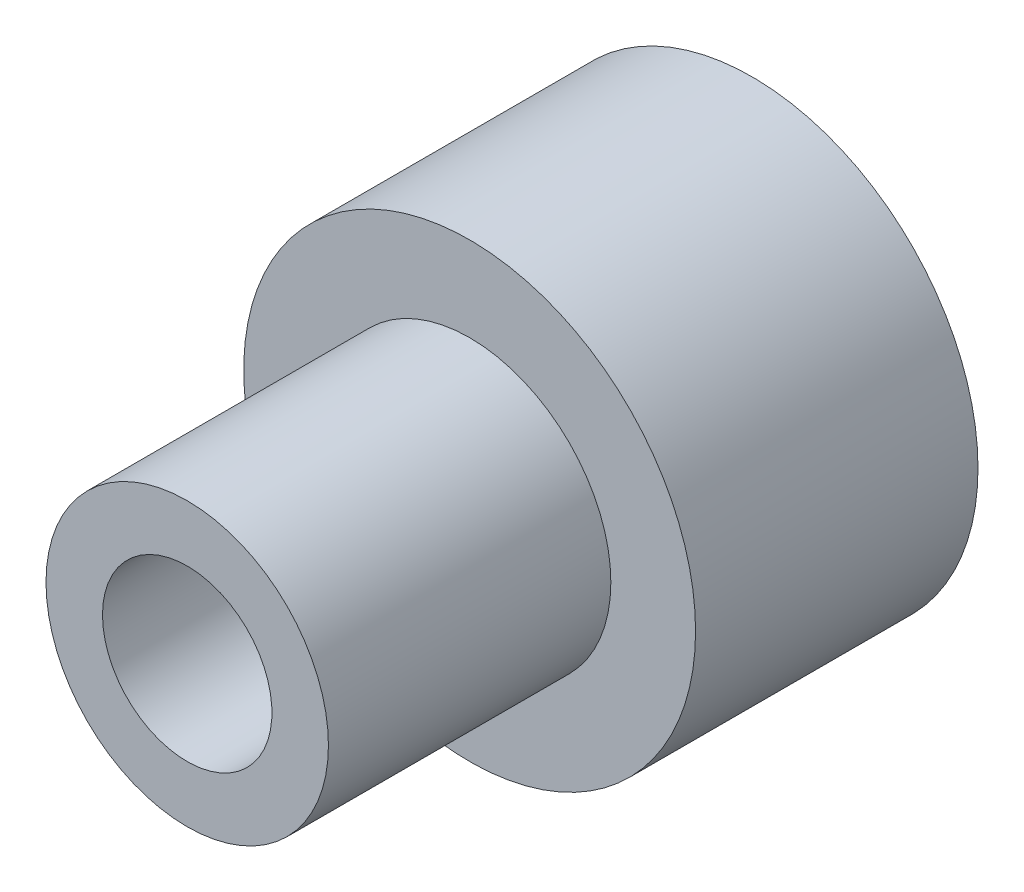
from build123d import *

# Parameters (mm, degrees)
SKETCH1_R           = 4
BOSS_EXTRUDE1_DEPTH = 5
SKETCH2_R           = 2.5
BOSS_EXTRUDE2_DEPTH = 5
SKETCH4_R           = 1.5
CUT_EXTRUDE2_DEPTH  = 10


with BuildPart() as part:
    # Sketch1 → Boss-Extrude1 (new body)
    with BuildSketch(Plane.XY):
        Circle(SKETCH1_R)
    extrude(amount=BOSS_EXTRUDE1_DEPTH)

    # Sketch2 → Boss-Extrude2 (add)
    with BuildSketch(Plane.XY.offset(5)):
        Circle(SKETCH2_R)
    extrude(amount=BOSS_EXTRUDE2_DEPTH)

    # Sketch4 → Cut-Extrude2 (cut)
    with BuildSketch(Plane(origin=(0, 0, 0), x_dir=(-1, 0, 0), z_dir=(0, 0, -1))):
        Circle(SKETCH4_R)
    extrude(amount=-CUT_EXTRUDE2_DEPTH, mode=Mode.SUBTRACT)


solid = part.part
